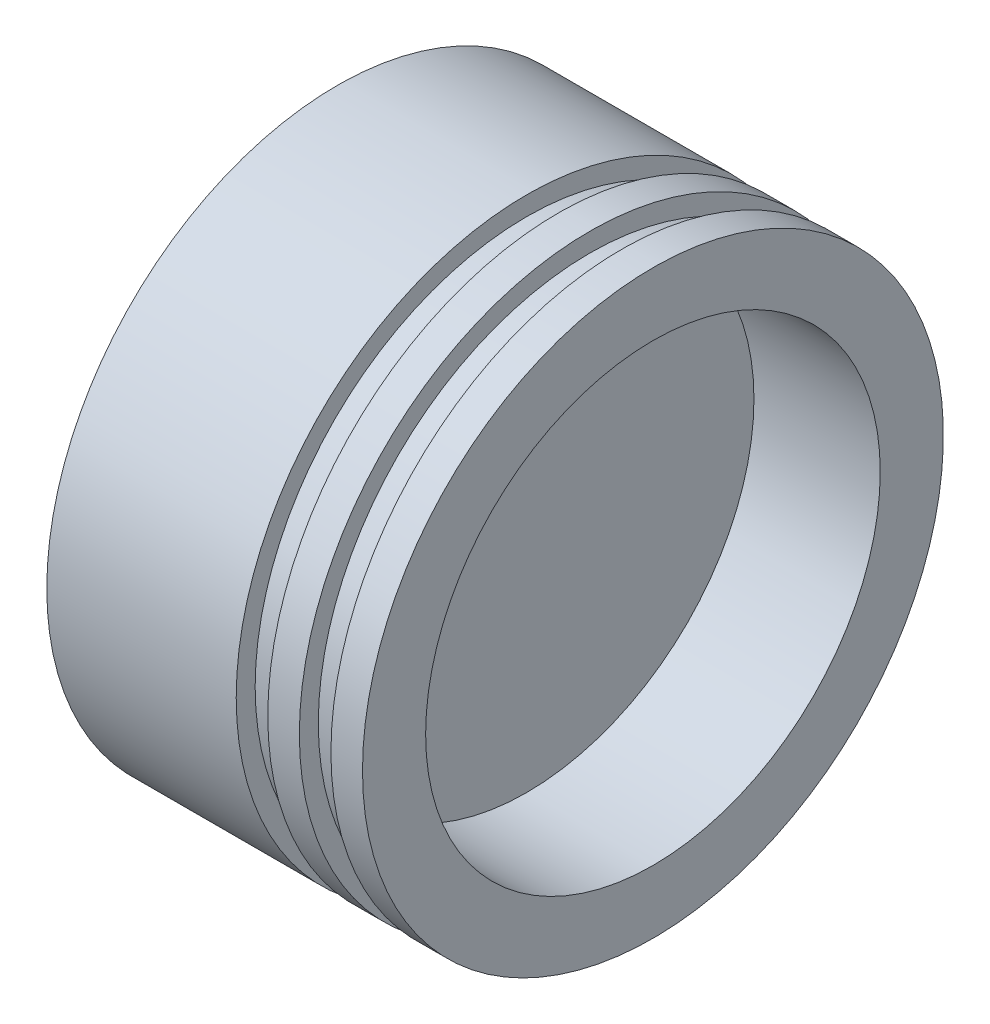
from build123d import *


with BuildPart() as part:
    # Sketch1 → Revolve1 (revolve)
    with BuildSketch(Plane.XY):
        Polygon((0, 0), (0, 46), (30, 46), (30, 43), (35, 43), (35, 46), (40, 46), (40, 43), (45, 43), (45, 46), (50, 46), (50, 36), (30, 36), (30, 0), align=None)
    revolve(axis=Axis((0, 0, 0), (1, 0, 0)))


solid = part.part
